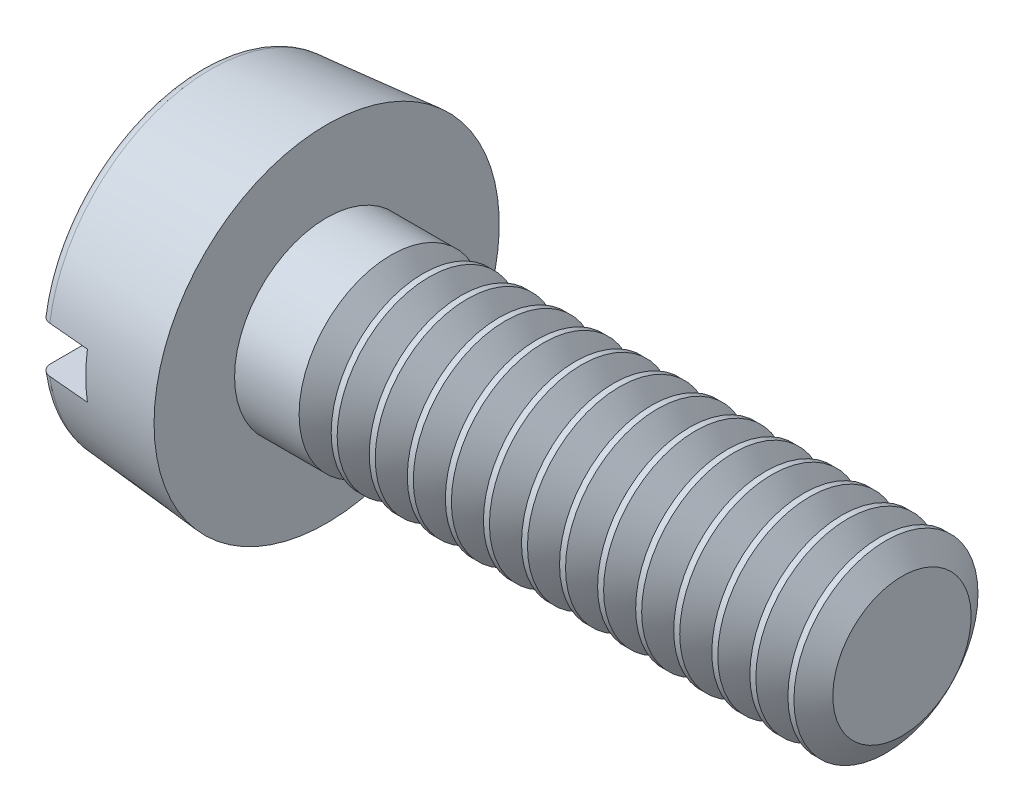
from build123d import *

# Parameters (mm, degrees)
FILLET2_R       = 0.1
SKETCH2_W       = 3
SKETCH2_H       = 0.4
SLOT_DEPTH      = 0.45
THDSCHPAT_COUNT = 14
THDSCHPAT_PITCH = 0.330769231


with BuildPart() as part:
    # BodySke → Base-Revolve (revolve)
    with BuildSketch(Plane.XY):
        Polygon((1.1, 0.8), (1.1, 1.5), (0, 1.40376247), (0, 0), (6.1, 0), (6.1, 0.8), align=None)
    revolve(axis=Axis((-25.4, 0, 0), (1, 0, 0)))

    # Fillet2
    fillet2_edges = [part.edges().sort_by_distance(p)[0] for p in [
        (0, -1.40376247, 0),
    ]]
    fillet(fillet2_edges, radius=FILLET2_R)

    # Sketch2 → Slot (cut)
    with BuildSketch(Plane(origin=(0, 0, 0), x_dir=(0, 0, -1), z_dir=(1, 0, 0))):
        Rectangle(SKETCH2_W, SKETCH2_H)
    extrude(amount=SLOT_DEPTH, mode=Mode.SUBTRACT)

    # ThdSchSke → ThreadSchematic (revolve, cut)
    with BuildSketch(Plane.XY):
        Polygon((1.8, -0.601), (1.6606587, -0.8), (1.6606587, -1), (1.9393413, -1), (1.9393413, -0.8), align=None)
    threadschematic = revolve(axis=Axis((-3.175, 0, 0), (1, 0, 0)), mode=Mode.SUBTRACT)

    # ThdSchPat: ThreadSchematic ×14
    with Locations(*[(i * THDSCHPAT_PITCH, 0, 0) for i in range(1, THDSCHPAT_COUNT)]):
        add(threadschematic, mode=Mode.SUBTRACT)


solid = part.part
